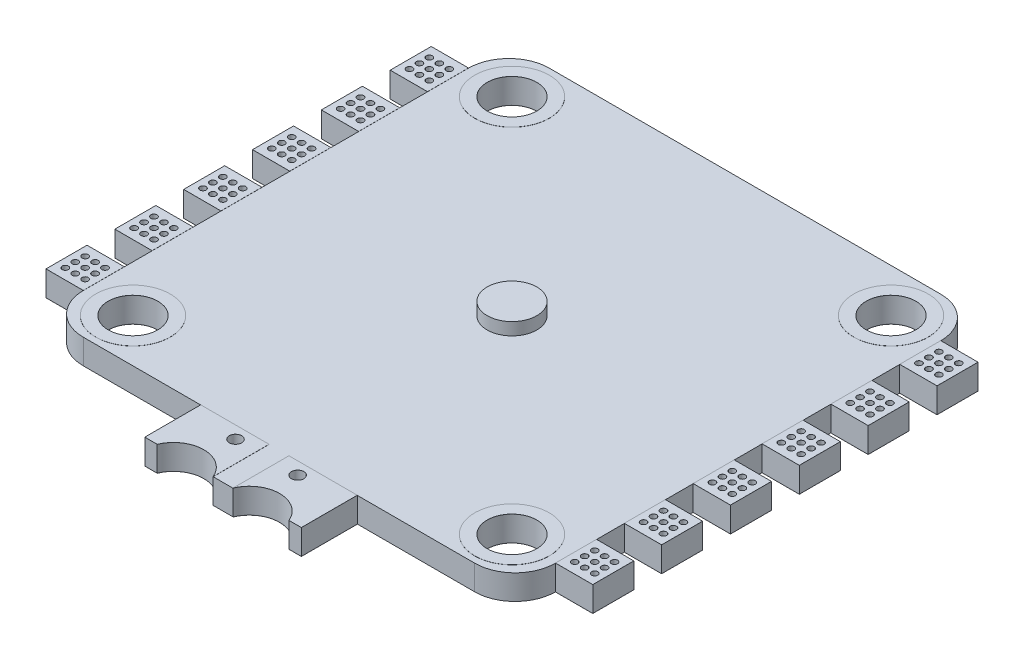
from build123d import *

# Parameters (mm, degrees)
SKETCH1_W               = 38
SKETCH1_H               = 37.5
SKETCH1_R               = 2
BOSS_EXTRUDE1_DEPTH     = 1
FILLET1_R               = 3.25
SKETCH2_W               = 3
SKETCH2_H               = 3.3
BOSS_EXTRUDE2_DEPTH     = 2
BOSS_EXTRUDE3_DEPTH     = 2
SKETCH4_R               = 3
SKETCH4_R_2             = 2
BOSS_EXTRUDE4_DEPTH     = 0.01
BOSS_EXTRUDE4_2_DEPTH   = 0.01
BOSS_EXTRUDE4_3_DEPTH   = 0.01
BOSS_EXTRUDE4_4_DEPTH   = 0.01
CUT_EXTRUDE1_START      = -3.01
SKETCH5_R               = 0.25
CUT_EXTRUDE1_DEPTH      = 4.02
SKETCH6_W               = 3
SKETCH6_H               = 3.3
SKETCH6_R               = 0.25
BOSS_EXTRUDE5_DEPTH     = 0.01
LPATTERN10_COUNT        = 6
LPATTERN10_PITCH        = 5.54
MIRROR3_START           = -3.01
MIRROR3_COPY_1_SKETCH_R = 0.25
MIRROR3_COPY_1_DEPTH    = 4.02
MIRROR3_COPY_2_SKETCH_R = 0.25
MIRROR3_COPY_2_DEPTH    = 4.02
MIRROR3_COPY_3_SKETCH_R = 0.25
MIRROR3_COPY_3_DEPTH    = 4.02
MIRROR3_COPY_4_SKETCH_R = 0.25
MIRROR3_COPY_4_DEPTH    = 4.02
MIRROR3_COPY_5_SKETCH_R = 0.25
MIRROR3_COPY_5_DEPTH    = 4.02
LPATTERN11_COUNT        = 6
LPATTERN11_PITCH        = 5.54
SKETCH7_R               = 0.5
CUT_EXTRUDE2_DEPTH      = 1.01
CUT_EXTRUDE2_DEPTH_BACK = 3.01
SKETCH8_R               = 0.5
BOSS_EXTRUDE6_DEPTH     = 0.01
BOSS_EXTRUDE6_2_DEPTH   = 0.01
SKETCH9_R               = 2
BOSS_EXTRUDE7_DEPTH     = 1


with BuildPart() as part:
    # Sketch1 → Boss-Extrude1 (new body, symmetric)
    with BuildSketch(Plane(origin=(0, 0, 0), x_dir=(1, 0, 0), z_dir=(0, 1, 0))):
        Rectangle(SKETCH1_W, SKETCH1_H)
        with Locations((-15.25, 15.25)):
            Circle(SKETCH1_R, mode=Mode.SUBTRACT)
        with Locations((15.25, 15.25)):
            Circle(SKETCH1_R, mode=Mode.SUBTRACT)
        with Locations((15.25, -15.25)):
            Circle(SKETCH1_R, mode=Mode.SUBTRACT)
        with Locations((-15.25, -15.25)):
            Circle(SKETCH1_R, mode=Mode.SUBTRACT)
    extrude(amount=BOSS_EXTRUDE1_DEPTH, both=True)

    # Fillet1
    fillet1_edges = [part.edges().sort_by_distance(p)[0] for p in [
        (-19, 0, -18.75),
        (19, 0, -18.75),
        (19, 0, 18.75),
        (-19, 0, 18.75),
    ]]
    fillet(fillet1_edges, radius=FILLET1_R)

    # Sketch2 → Boss-Extrude2 (add)
    with BuildSketch(Plane(origin=(0, 1, 0), x_dir=(1, 0, 0), z_dir=(0, 1, 0))):
        with Locations((-20.5, 8.31)):
            Rectangle(SKETCH2_W, SKETCH2_H)
        with Locations((-20.5, 13.85)):
            Rectangle(SKETCH2_W, SKETCH2_H)
        with Locations((-20.5, 2.77)):
            Rectangle(SKETCH2_W, SKETCH2_H)
        with Locations((-20.5, -2.77)):
            Rectangle(SKETCH2_W, SKETCH2_H)
        with Locations((-20.5, -8.31)):
            Rectangle(SKETCH2_W, SKETCH2_H)
        with Locations((-20.5, -13.85)):
            Rectangle(SKETCH2_W, SKETCH2_H)
    boss_extrude2 = extrude(amount=-BOSS_EXTRUDE2_DEPTH)

    # Mirror1: Boss-Extrude2 across plane
    add(boss_extrude2.mirror(Plane(origin=(0, 0, 0), x_dir=(0, 0, 1), z_dir=(1, 0, 0))))

    # Sketch3 → Boss-Extrude3 (add)
    with BuildSketch(Plane(origin=(0, 1, 0), x_dir=(1, 0, 0), z_dir=(0, 1, 0))):
        with BuildLine():
            Line((-6.3, -18.75), (6.3, -18.75))
            Line((6.3, -18.75), (6.3, -23.25))
            Line((6.3, -23.25), (5.3, -23.25))
            ThreePointArc((5.3, -23.25), (3.05, -21.75), (0.8, -23.25))
            Line((0.8, -23.25), (-0.8, -23.25))
            ThreePointArc((-0.8, -23.25), (-3.05, -21.75), (-5.3, -23.25))
            Line((-5.3, -23.25), (-6.3, -23.25))
            Line((-6.3, -23.25), (-6.3, -18.75))
        make_face()
    extrude(amount=-BOSS_EXTRUDE3_DEPTH)

    # Sketch5 → Cut-Extrude1 (cut)
    with BuildSketch(Plane(origin=(0, 1, 0), x_dir=(1, 0, 0), z_dir=(0, 1, 0)).offset(CUT_EXTRUDE1_START)):
        with Locations((-21.3, -14.65)):
            Circle(SKETCH5_R)
        with Locations((-20.5, -14.65)):
            Circle(SKETCH5_R)
        with Locations((-19.7, -14.65)):
            Circle(SKETCH5_R)
        with Locations((-20.5, -13.85)):
            Circle(SKETCH5_R)
        with Locations((-19.7, -13.85)):
            Circle(SKETCH5_R)
        with Locations((-20.5, -13.05)):
            Circle(SKETCH5_R)
        with Locations((-19.7, -13.05)):
            Circle(SKETCH5_R)
        with Locations((-21.3, -13.85)):
            Circle(SKETCH5_R)
        with Locations((-21.3, -13.05)):
            Circle(SKETCH5_R)
    cut_extrude1 = extrude(amount=CUT_EXTRUDE1_DEPTH, mode=Mode.SUBTRACT)

    # LPattern10: Cut-Extrude1 ×6
    with Locations(*[(0, 0, -i * LPATTERN10_PITCH) for i in range(1, LPATTERN10_COUNT)]):
        add(cut_extrude1, mode=Mode.SUBTRACT)

    # Mirror3: Cut-Extrude1 across plane
    add(cut_extrude1.mirror(Plane(origin=(0, 0, 0), x_dir=(0, 0, 1), z_dir=(1, 0, 0))), mode=Mode.SUBTRACT)

    # Mirror3 copy 1 sketch → Mirror3 copy 1 (cut)
    with BuildSketch(Plane(origin=(0, 1, -5.54), x_dir=(-1, 0, 0), z_dir=(0, 1, 0)).offset(MIRROR3_START)):
        with Locations((-21.3, 14.65)):
            Circle(MIRROR3_COPY_1_SKETCH_R)
        with Locations((-20.5, 14.65)):
            Circle(MIRROR3_COPY_1_SKETCH_R)
        with Locations((-19.7, 14.65)):
            Circle(MIRROR3_COPY_1_SKETCH_R)
        with Locations((-20.5, 13.85)):
            Circle(MIRROR3_COPY_1_SKETCH_R)
        with Locations((-19.7, 13.85)):
            Circle(MIRROR3_COPY_1_SKETCH_R)
        with Locations((-20.5, 13.05)):
            Circle(MIRROR3_COPY_1_SKETCH_R)
        with Locations((-19.7, 13.05)):
            Circle(MIRROR3_COPY_1_SKETCH_R)
        with Locations((-21.3, 13.85)):
            Circle(MIRROR3_COPY_1_SKETCH_R)
        with Locations((-21.3, 13.05)):
            Circle(MIRROR3_COPY_1_SKETCH_R)
    extrude(amount=MIRROR3_COPY_1_DEPTH, mode=Mode.SUBTRACT)

    # Mirror3 copy 2 sketch → Mirror3 copy 2 (cut)
    with BuildSketch(Plane(origin=(0, 1, -11.08), x_dir=(-1, 0, 0), z_dir=(0, 1, 0)).offset(MIRROR3_START)):
        with Locations((-21.3, 14.65)):
            Circle(MIRROR3_COPY_2_SKETCH_R)
        with Locations((-20.5, 14.65)):
            Circle(MIRROR3_COPY_2_SKETCH_R)
        with Locations((-19.7, 14.65)):
            Circle(MIRROR3_COPY_2_SKETCH_R)
        with Locations((-20.5, 13.85)):
            Circle(MIRROR3_COPY_2_SKETCH_R)
        with Locations((-19.7, 13.85)):
            Circle(MIRROR3_COPY_2_SKETCH_R)
        with Locations((-20.5, 13.05)):
            Circle(MIRROR3_COPY_2_SKETCH_R)
        with Locations((-19.7, 13.05)):
            Circle(MIRROR3_COPY_2_SKETCH_R)
        with Locations((-21.3, 13.85)):
            Circle(MIRROR3_COPY_2_SKETCH_R)
        with Locations((-21.3, 13.05)):
            Circle(MIRROR3_COPY_2_SKETCH_R)
    extrude(amount=MIRROR3_COPY_2_DEPTH, mode=Mode.SUBTRACT)

    # Mirror3 copy 3 sketch → Mirror3 copy 3 (cut)
    with BuildSketch(Plane(origin=(0, 1, -16.62), x_dir=(-1, 0, 0), z_dir=(0, 1, 0)).offset(MIRROR3_START)):
        with Locations((-21.3, 14.65)):
            Circle(MIRROR3_COPY_3_SKETCH_R)
        with Locations((-20.5, 14.65)):
            Circle(MIRROR3_COPY_3_SKETCH_R)
        with Locations((-19.7, 14.65)):
            Circle(MIRROR3_COPY_3_SKETCH_R)
        with Locations((-20.5, 13.85)):
            Circle(MIRROR3_COPY_3_SKETCH_R)
        with Locations((-19.7, 13.85)):
            Circle(MIRROR3_COPY_3_SKETCH_R)
        with Locations((-20.5, 13.05)):
            Circle(MIRROR3_COPY_3_SKETCH_R)
        with Locations((-19.7, 13.05)):
            Circle(MIRROR3_COPY_3_SKETCH_R)
        with Locations((-21.3, 13.85)):
            Circle(MIRROR3_COPY_3_SKETCH_R)
        with Locations((-21.3, 13.05)):
            Circle(MIRROR3_COPY_3_SKETCH_R)
    extrude(amount=MIRROR3_COPY_3_DEPTH, mode=Mode.SUBTRACT)

    # Mirror3 copy 4 sketch → Mirror3 copy 4 (cut)
    with BuildSketch(Plane(origin=(0, 1, -22.16), x_dir=(-1, 0, 0), z_dir=(0, 1, 0)).offset(MIRROR3_START)):
        with Locations((-21.3, 14.65)):
            Circle(MIRROR3_COPY_4_SKETCH_R)
        with Locations((-20.5, 14.65)):
            Circle(MIRROR3_COPY_4_SKETCH_R)
        with Locations((-19.7, 14.65)):
            Circle(MIRROR3_COPY_4_SKETCH_R)
        with Locations((-20.5, 13.85)):
            Circle(MIRROR3_COPY_4_SKETCH_R)
        with Locations((-19.7, 13.85)):
            Circle(MIRROR3_COPY_4_SKETCH_R)
        with Locations((-20.5, 13.05)):
            Circle(MIRROR3_COPY_4_SKETCH_R)
        with Locations((-19.7, 13.05)):
            Circle(MIRROR3_COPY_4_SKETCH_R)
        with Locations((-21.3, 13.85)):
            Circle(MIRROR3_COPY_4_SKETCH_R)
        with Locations((-21.3, 13.05)):
            Circle(MIRROR3_COPY_4_SKETCH_R)
    extrude(amount=MIRROR3_COPY_4_DEPTH, mode=Mode.SUBTRACT)

    # Mirror3 copy 5 sketch → Mirror3 copy 5 (cut)
    with BuildSketch(Plane(origin=(0, 1, -27.7), x_dir=(-1, 0, 0), z_dir=(0, 1, 0)).offset(MIRROR3_START)):
        with Locations((-21.3, 14.65)):
            Circle(MIRROR3_COPY_5_SKETCH_R)
        with Locations((-20.5, 14.65)):
            Circle(MIRROR3_COPY_5_SKETCH_R)
        with Locations((-19.7, 14.65)):
            Circle(MIRROR3_COPY_5_SKETCH_R)
        with Locations((-20.5, 13.85)):
            Circle(MIRROR3_COPY_5_SKETCH_R)
        with Locations((-19.7, 13.85)):
            Circle(MIRROR3_COPY_5_SKETCH_R)
        with Locations((-20.5, 13.05)):
            Circle(MIRROR3_COPY_5_SKETCH_R)
        with Locations((-19.7, 13.05)):
            Circle(MIRROR3_COPY_5_SKETCH_R)
        with Locations((-21.3, 13.85)):
            Circle(MIRROR3_COPY_5_SKETCH_R)
        with Locations((-21.3, 13.05)):
            Circle(MIRROR3_COPY_5_SKETCH_R)
    extrude(amount=MIRROR3_COPY_5_DEPTH, mode=Mode.SUBTRACT)


with BuildPart() as body_2:
    # Sketch4 → Boss-Extrude4 (new body)
    with BuildSketch(Plane(origin=(0, 1, 0), x_dir=(1, 0, 0), z_dir=(0, 1, 0))):
        with Locations((-15.25, 15.25)):
            Circle(SKETCH4_R)
        with Locations((-15.25, 15.25)):
            Circle(SKETCH4_R_2, mode=Mode.SUBTRACT)
    extrude(amount=BOSS_EXTRUDE4_DEPTH)


with BuildPart() as body_3:
    # Sketch4 → Boss-Extrude4 2 (new body)
    with BuildSketch(Plane(origin=(0, 1, 0), x_dir=(1, 0, 0), z_dir=(0, 1, 0))):
        with Locations((15.25, 15.25)):
            Circle(SKETCH4_R)
        with Locations((15.25, 15.25)):
            Circle(SKETCH4_R_2, mode=Mode.SUBTRACT)
    extrude(amount=BOSS_EXTRUDE4_2_DEPTH)


with BuildPart() as body_4:
    # Sketch4 → Boss-Extrude4 3 (new body)
    with BuildSketch(Plane(origin=(0, 1, 0), x_dir=(1, 0, 0), z_dir=(0, 1, 0))):
        with Locations((15.25, -15.25)):
            Circle(SKETCH4_R)
        with Locations((15.25, -15.25)):
            Circle(SKETCH4_R_2, mode=Mode.SUBTRACT)
    extrude(amount=BOSS_EXTRUDE4_3_DEPTH)


with BuildPart() as body_5:
    # Sketch4 → Boss-Extrude4 4 (new body)
    with BuildSketch(Plane(origin=(0, 1, 0), x_dir=(1, 0, 0), z_dir=(0, 1, 0))):
        with Locations((-15.25, -15.25)):
            Circle(SKETCH4_R)
        with Locations((-15.25, -15.25)):
            Circle(SKETCH4_R_2, mode=Mode.SUBTRACT)
    extrude(amount=BOSS_EXTRUDE4_4_DEPTH)


with BuildPart() as body_6:
    # Mirror2: mirrored copy
    add(body_2.part.mirror(Plane.ZX))


with BuildPart() as body_7:
    # Mirror2 2: mirrored copy
    add(body_5.part.mirror(Plane.ZX))


with BuildPart() as body_8:
    # Mirror2 3: mirrored copy
    add(body_4.part.mirror(Plane.ZX))


with BuildPart() as body_9:
    # Mirror2 4: mirrored copy
    add(body_3.part.mirror(Plane.ZX))


with BuildPart() as body_10:
    # Sketch6 → Boss-Extrude5 (new body)
    with BuildSketch(Plane(origin=(0, 1, 0), x_dir=(1, 0, 0), z_dir=(0, 1, 0))):
        with Locations((-20.5, -13.85)):
            Rectangle(SKETCH6_W, SKETCH6_H)
        with Locations((-19.7, -13.05)):
            Circle(SKETCH6_R, mode=Mode.SUBTRACT)
        with Locations((-20.5, -13.05)):
            Circle(SKETCH6_R, mode=Mode.SUBTRACT)
        with Locations((-20.5, -13.85)):
            Circle(SKETCH6_R, mode=Mode.SUBTRACT)
        with Locations((-19.7, -13.85)):
            Circle(SKETCH6_R, mode=Mode.SUBTRACT)
        with Locations((-19.7, -14.65)):
            Circle(SKETCH6_R, mode=Mode.SUBTRACT)
        with Locations((-20.5, -14.65)):
            Circle(SKETCH6_R, mode=Mode.SUBTRACT)
        with Locations((-21.3, -14.65)):
            Circle(SKETCH6_R, mode=Mode.SUBTRACT)
        with Locations((-21.3, -13.85)):
            Circle(SKETCH6_R, mode=Mode.SUBTRACT)
        with Locations((-21.3, -13.05)):
            Circle(SKETCH6_R, mode=Mode.SUBTRACT)
    extrude(amount=BOSS_EXTRUDE5_DEPTH)


with BuildPart() as lpattern11_1:
    # LPattern11: pattern copy
    add(body_10.part.moved(Location(Vector(0, 0, -1) * (1 * LPATTERN11_PITCH))))


with BuildPart() as lpattern11_2:
    # LPattern11: pattern copy
    add(body_10.part.moved(Location(Vector(0, 0, -1) * (2 * LPATTERN11_PITCH))))


with BuildPart() as lpattern11_3:
    # LPattern11: pattern copy
    add(body_10.part.moved(Location(Vector(0, 0, -1) * (3 * LPATTERN11_PITCH))))


with BuildPart() as lpattern11_4:
    # LPattern11: pattern copy
    add(body_10.part.moved(Location(Vector(0, 0, -1) * (4 * LPATTERN11_PITCH))))


with BuildPart() as lpattern11_5:
    # LPattern11: pattern copy
    add(body_10.part.moved(Location(Vector(0, 0, -1) * (5 * LPATTERN11_PITCH))))


with BuildPart() as body_16:
    # Mirror4: mirrored copy
    add(body_10.part.mirror(Plane(origin=(0, 0, 0), x_dir=(0, 0, 1), z_dir=(1, 0, 0))))


with BuildPart() as body_17:
    # Mirror4 2: mirrored copy
    add(lpattern11_5.part.mirror(Plane(origin=(0, 0, 0), x_dir=(0, 0, 1), z_dir=(1, 0, 0))))


with BuildPart() as body_18:
    # Mirror4 3: mirrored copy
    add(lpattern11_4.part.mirror(Plane(origin=(0, 0, 0), x_dir=(0, 0, 1), z_dir=(1, 0, 0))))


with BuildPart() as body_19:
    # Mirror4 4: mirrored copy
    add(lpattern11_3.part.mirror(Plane(origin=(0, 0, 0), x_dir=(0, 0, 1), z_dir=(1, 0, 0))))


with BuildPart() as body_20:
    # Mirror4 5: mirrored copy
    add(lpattern11_2.part.mirror(Plane(origin=(0, 0, 0), x_dir=(0, 0, 1), z_dir=(1, 0, 0))))


with BuildPart() as body_21:
    # Mirror4 6: mirrored copy
    add(lpattern11_1.part.mirror(Plane(origin=(0, 0, 0), x_dir=(0, 0, 1), z_dir=(1, 0, 0))))


with BuildPart() as body_22:
    # Mirror4 7: mirrored copy
    add(part.part.mirror(Plane(origin=(0, 0, 0), x_dir=(0, 0, 1), z_dir=(1, 0, 0))))


with BuildPart() as body_22_2:
    # Mirror5: mirrored copy
    add(lpattern11_1.part.mirror(Plane.ZX))


with BuildPart() as body_23:
    # Mirror5 2: mirrored copy
    add(body_21.part.mirror(Plane.ZX))


with BuildPart() as body_24:
    # Mirror5 3: mirrored copy
    add(body_20.part.mirror(Plane.ZX))


with BuildPart() as body_25:
    # Mirror5 4: mirrored copy
    add(body_19.part.mirror(Plane.ZX))


with BuildPart() as body_26:
    # Mirror5 5: mirrored copy
    add(body_18.part.mirror(Plane.ZX))


with BuildPart() as body_27:
    # Mirror5 6: mirrored copy
    add(body_17.part.mirror(Plane.ZX))


with BuildPart() as body_28:
    # Mirror5 7: mirrored copy
    add(body_16.part.mirror(Plane.ZX))


with BuildPart() as body_29:
    # Mirror5 8: mirrored copy
    add(lpattern11_5.part.mirror(Plane.ZX))


with BuildPart() as body_30:
    # Mirror5 9: mirrored copy
    add(lpattern11_4.part.mirror(Plane.ZX))


with BuildPart() as body_31:
    # Mirror5 10: mirrored copy
    add(lpattern11_3.part.mirror(Plane.ZX))


with BuildPart() as body_32:
    # Mirror5 11: mirrored copy
    add(lpattern11_2.part.mirror(Plane.ZX))


with BuildPart() as body_33:
    # Mirror5 12: mirrored copy
    add(body_10.part.mirror(Plane.ZX))


with BuildPart() as part_1:
    add(part.part)

    # Sketch7 → Cut-Extrude2 (cut, two sides)
    with BuildSketch(Plane(origin=(0, 1, 0), x_dir=(1, 0, 0), z_dir=(0, 1, 0))) as cut_extrude2_sk:
        with Locations((-2.5, -19.75)):
            Circle(SKETCH7_R)
        with Locations((2.5, -19.75)):
            Circle(SKETCH7_R)
    extrude(amount=CUT_EXTRUDE2_DEPTH, mode=Mode.SUBTRACT)
    extrude(cut_extrude2_sk.sketch, amount=-CUT_EXTRUDE2_DEPTH_BACK, mode=Mode.SUBTRACT)


with BuildPart() as body_34:
    # Sketch8 → Boss-Extrude6 (new body)
    with BuildSketch(Plane(origin=(0, 1, 0), x_dir=(1, 0, 0), z_dir=(0, 1, 0))):
        with BuildLine():
            Line((5.3, -23.25), (6.3, -23.25))
            Line((6.3, -23.25), (6.3, -18.75))
            Line((6.3, -18.75), (0.8, -18.75))
            Line((0.8, -18.75), (0.8, -23.25))
            ThreePointArc((0.8, -23.25), (3.05, -21.75), (5.3, -23.25))
        make_face()
        with Locations((2.5, -19.75)):
            Circle(SKETCH8_R, mode=Mode.SUBTRACT)
    extrude(amount=BOSS_EXTRUDE6_DEPTH)


with BuildPart() as body_35:
    # Sketch8 → Boss-Extrude6 2 (new body)
    with BuildSketch(Plane(origin=(0, 1, 0), x_dir=(1, 0, 0), z_dir=(0, 1, 0))):
        with BuildLine():
            Line((-6.3, -23.25), (-5.3, -23.25))
            ThreePointArc((-5.3, -23.25), (-3.05, -21.75), (-0.8, -23.25))
            Line((-0.8, -23.25), (-0.8, -18.75))
            Line((-0.8, -18.75), (-6.3, -18.75))
            Line((-6.3, -18.75), (-6.3, -23.25))
        make_face()
        with Locations((-2.5, -19.75)):
            Circle(SKETCH8_R, mode=Mode.SUBTRACT)
    extrude(amount=BOSS_EXTRUDE6_2_DEPTH)


with BuildPart() as body_36:
    # Mirror6: mirrored copy
    add(body_34.part.mirror(Plane.ZX))


with BuildPart() as body_37:
    # Mirror6 2: mirrored copy
    add(body_35.part.mirror(Plane.ZX))


with BuildPart() as body_38:
    # Sketch9 → Boss-Extrude7 (new body)
    with BuildSketch(Plane(origin=(0, 1, 0), x_dir=(1, 0, 0), z_dir=(0, 1, 0))):
        Circle(SKETCH9_R)
    extrude(amount=BOSS_EXTRUDE7_DEPTH)


solid = Compound([body_2.part, body_3.part, body_4.part, body_5.part, body_6.part, body_7.part, body_8.part, body_9.part, body_10.part, lpattern11_1.part, lpattern11_2.part, lpattern11_3.part, lpattern11_4.part, lpattern11_5.part, body_16.part, body_17.part, body_18.part, body_19.part, body_20.part, body_21.part, body_22_2.part, body_23.part, body_24.part, body_25.part, body_26.part, body_27.part, body_28.part, body_29.part, body_30.part, body_31.part, body_32.part, body_33.part, part_1.part, body_34.part, body_35.part, body_36.part, body_37.part, body_38.part])
